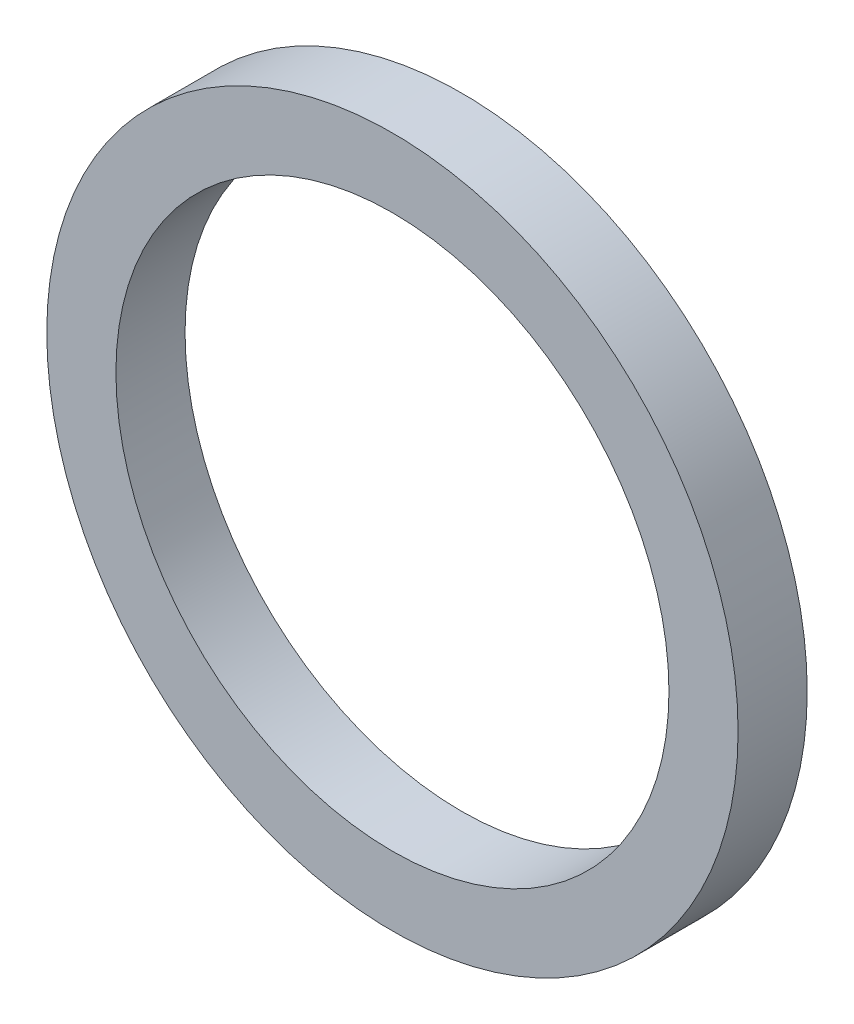
from build123d import *

# Parameters (mm, degrees)
SZKIC1_R                    = 5
SZKIC1_R_2                  = 4
DODANIE_WYCI_GNI_CIE1_DEPTH = 1


with BuildPart() as part:
    # Szkic1 → Dodanie-wyciągnięcie1 (new body)
    with BuildSketch(Plane.XY):
        Circle(SZKIC1_R)
        Circle(SZKIC1_R_2, mode=Mode.SUBTRACT)
    extrude(amount=DODANIE_WYCI_GNI_CIE1_DEPTH)


solid = part.part
